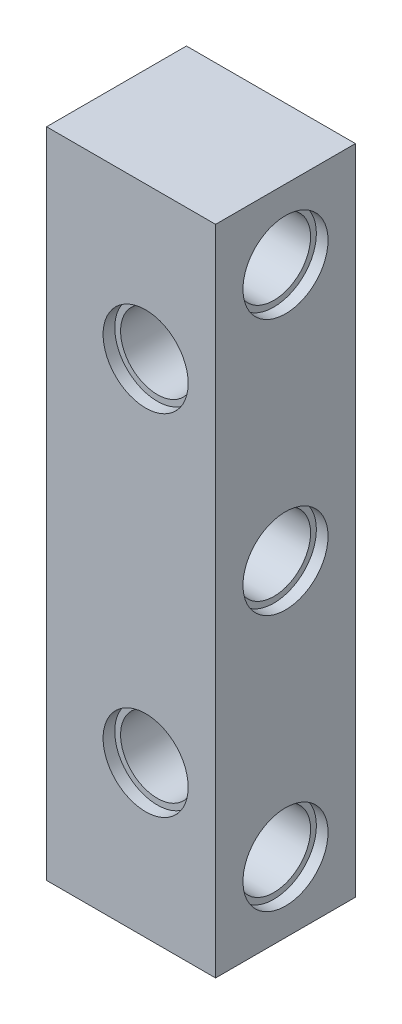
from build123d import *

# Parameters (mm, degrees)
ESQUISSE1_W                  = 12
ESQUISSE1_H                  = 40
BOSS_EXTRU_1_DEPTH           = 12
ESQUISSE3_R                  = 3.15
ENL_V_MAT_EXTRU_1_DEPTH      = 44.451121965
ENL_V_MAT_EXTRU_1_DEPTH_BACK = 44.451121965
ESQUISSE4_R                  = 3.15
ENL_V_MAT_EXTRU_2_DEPTH      = 44.451121965
ENL_V_MAT_EXTRU_2_DEPTH_BACK = 44.451121965
ESQUISSE5_R                  = 3.65
ENL_V_MAT_EXTRU_3_DEPTH      = 1
ESQUISSE6_R                  = 3.65
ENL_V_MAT_EXTRU_4_DEPTH      = 1
ESQUISSE7_W                  = 12
ESQUISSE7_H                  = 8
BOSS_EXTRU_2_DEPTH           = 12
ESQUISSE8_W                  = 1
ESQUISSE8_H                  = 12
ENL_V_MAT_EXTRU_5_DEPTH      = 59.514955353
ENL_V_MAT_EXTRU_5_DEPTH_BACK = 59.514955353
ESQUISSE9_R                  = 3.15
ENL_V_MAT_EXTRU_6_DEPTH      = 51.68530359
ENL_V_MAT_EXTRU_6_DEPTH_BACK = 51.68530359
ESQUISSE11_W                 = 12
ESQUISSE11_H                 = 56
ESQUISSE11_R                 = 3.15
BOSS_EXTRU_3_DEPTH           = 3.5
ESQUISSE12_R                 = 3.65
ENL_V_MAT_EXTRU_8_DEPTH      = 1
ESQUISSE13_R                 = 3.65
ENL_V_MAT_EXTRU_9_DEPTH      = 1


with BuildPart() as part:
    # Esquisse1 → Boss.-Extru.1 (new body)
    with BuildSketch(Plane.XY):
        with Locations((6, 20)):
            Rectangle(ESQUISSE1_W, ESQUISSE1_H)
    extrude(amount=BOSS_EXTRU_1_DEPTH)

    # Esquisse3 → Enlèv. mat.-Extru.1 (cut, two sides)
    with BuildSketch(Plane.XY.offset(12)) as enl_v_mat_extru_1_sk:
        with Locations((5, 5)):
            Circle(ESQUISSE3_R)
        with Locations((5, 35)):
            Circle(ESQUISSE3_R)
    extrude(amount=ENL_V_MAT_EXTRU_1_DEPTH, mode=Mode.SUBTRACT)
    extrude(enl_v_mat_extru_1_sk.sketch, amount=-ENL_V_MAT_EXTRU_1_DEPTH_BACK, mode=Mode.SUBTRACT)

    # Esquisse4 → Enlèv. mat.-Extru.2 (cut, two sides)
    with BuildSketch(Plane(origin=(12, 0, 0), x_dir=(0, 0, -1), z_dir=(1, 0, 0))) as enl_v_mat_extru_2_sk:
        with Locations((-6, 20)):
            Circle(ESQUISSE4_R)
    extrude(amount=ENL_V_MAT_EXTRU_2_DEPTH, mode=Mode.SUBTRACT)
    extrude(enl_v_mat_extru_2_sk.sketch, amount=-ENL_V_MAT_EXTRU_2_DEPTH_BACK, mode=Mode.SUBTRACT)

    # Esquisse5 → Enlèv. mat.-Extru.3 (cut)
    with BuildSketch(Plane.XY.offset(12)):
        with Locations((5, 35)):
            Circle(ESQUISSE5_R)
        with Locations((5, 5)):
            Circle(ESQUISSE5_R)
    extrude(amount=-ENL_V_MAT_EXTRU_3_DEPTH, mode=Mode.SUBTRACT)

    # Esquisse6 → Enlèv. mat.-Extru.4 (cut)
    with BuildSketch(Plane(origin=(12, 0, 0), x_dir=(0, 0, -1), z_dir=(1, 0, 0))):
        with Locations((-6, 20)):
            Circle(ESQUISSE6_R)
    extrude(amount=-ENL_V_MAT_EXTRU_4_DEPTH, mode=Mode.SUBTRACT)

    # Esquisse7 → Boss.-Extru.2 (add)
    with BuildSketch(Plane(origin=(12, 0, 0), x_dir=(0, 0, -1), z_dir=(1, 0, 0))):
        with Locations((-6, -4)):
            Rectangle(ESQUISSE7_W, ESQUISSE7_H)
        with Locations((-6, 44)):
            Rectangle(ESQUISSE7_W, ESQUISSE7_H)
    extrude(amount=-BOSS_EXTRU_2_DEPTH)

    # Esquisse8 → Enlèv. mat.-Extru.5 (cut, two sides)
    with BuildSketch(Plane.XZ.offset(8)) as enl_v_mat_extru_5_sk:
        with Locations((11.5, 6)):
            Rectangle(ESQUISSE8_W, ESQUISSE8_H)
    extrude(amount=ENL_V_MAT_EXTRU_5_DEPTH, mode=Mode.SUBTRACT)
    extrude(enl_v_mat_extru_5_sk.sketch, amount=-ENL_V_MAT_EXTRU_5_DEPTH_BACK, mode=Mode.SUBTRACT)

    # Esquisse9 → Enlèv. mat.-Extru.6 (cut, two sides)
    with BuildSketch(Plane(origin=(11, 0, 0), x_dir=(0, 0, -1), z_dir=(1, 0, 0))) as enl_v_mat_extru_6_sk:
        with Locations((-6, 42)):
            Circle(ESQUISSE9_R)
        with Locations((-6, -2)):
            Circle(ESQUISSE9_R)
    extrude(amount=ENL_V_MAT_EXTRU_6_DEPTH, mode=Mode.SUBTRACT)
    extrude(enl_v_mat_extru_6_sk.sketch, amount=-ENL_V_MAT_EXTRU_6_DEPTH_BACK, mode=Mode.SUBTRACT)

    # Esquisse11 → Boss.-Extru.3 (add)
    with BuildSketch(Plane.ZY):
        with Locations((6, 20)):
            Rectangle(ESQUISSE11_W, ESQUISSE11_H)
        with Locations(Location((6, -2, 0), (0, 0, 180))):
            Circle(ESQUISSE11_R, mode=Mode.SUBTRACT)
        with Locations(Location((6, 20, 0), (0, 0, 180))):
            Circle(ESQUISSE11_R, mode=Mode.SUBTRACT)
        with Locations(Location((6, 42, 0), (0, 0, 180))):
            Circle(ESQUISSE11_R, mode=Mode.SUBTRACT)
    extrude(amount=BOSS_EXTRU_3_DEPTH)

    # Esquisse12 → Enlèv. mat.-Extru.8 (cut)
    with BuildSketch(Plane.ZY.offset(3.5)):
        with Locations((6, 42)):
            Circle(ESQUISSE12_R)
        with Locations((6, 20)):
            Circle(ESQUISSE12_R)
        with Locations((6, -2)):
            Circle(ESQUISSE12_R)
    extrude(amount=-ENL_V_MAT_EXTRU_8_DEPTH, mode=Mode.SUBTRACT)

    # Esquisse13 → Enlèv. mat.-Extru.9 (cut)
    with BuildSketch(Plane(origin=(11, 0, 0), x_dir=(0, 0, -1), z_dir=(1, 0, 0))):
        with Locations(Location((-6, -2, 0), (0, 0, 180))):
            Circle(ESQUISSE13_R)
        with Locations(Location((-6, 20, 0), (0, 0, 180))):
            Circle(ESQUISSE13_R)
        with Locations(Location((-6, 42, 0), (0, 0, 180))):
            Circle(ESQUISSE13_R)
    extrude(amount=-ENL_V_MAT_EXTRU_9_DEPTH, mode=Mode.SUBTRACT)


solid = part.part
